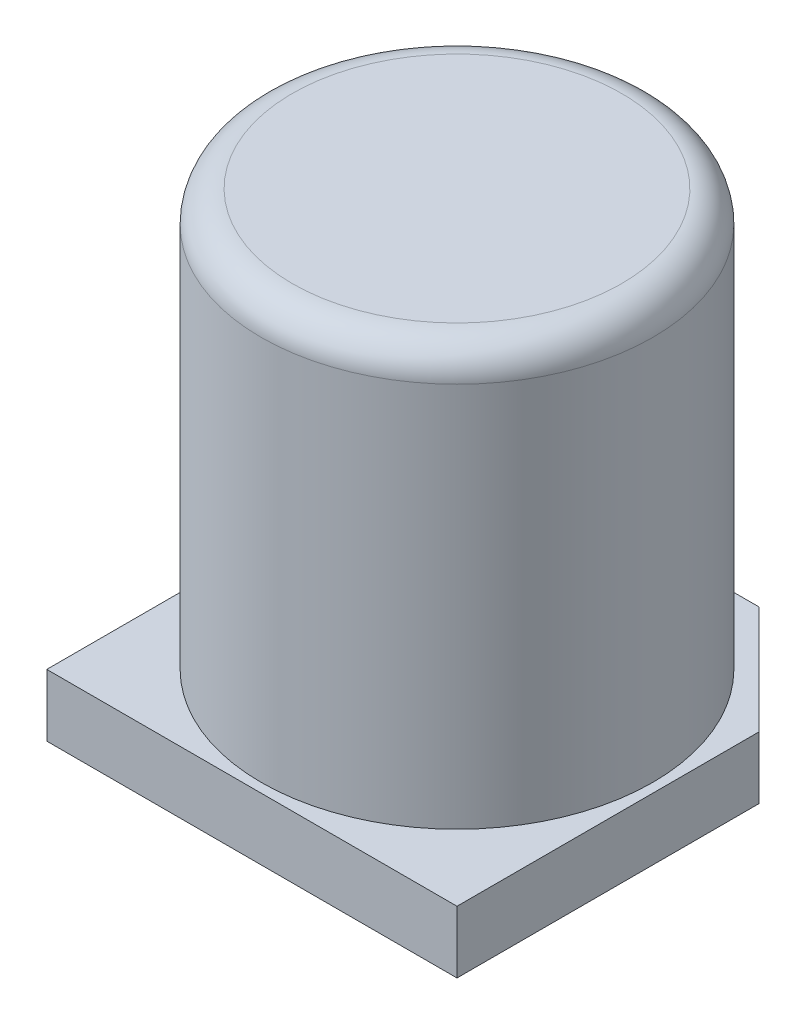
from build123d import *

# Parameters (mm, degrees)
ESBO_O1_W                = 6.6
ESBO_O1_H                = 6.6
RESSALTO_EXTRUS_O1_DEPTH = 1
ESBO_O2_W                = 3.15
ESBO_O2_H                = 6.7
CHANFRO1_SIZE            = 1.737451731
FILETE1_R                = 0.5


with BuildPart() as part:
    # Esboço1 → Ressalto-extrusão1 (new body)
    with BuildSketch(Plane.XZ):
        Rectangle(ESBO_O1_W, ESBO_O1_H)
    extrude(amount=-RESSALTO_EXTRUS_O1_DEPTH)

    # Esboço2 → Revolução1 (revolve)
    with BuildSketch(Plane.XY):
        with Locations((1.575, 4.35)):
            Rectangle(ESBO_O2_W, ESBO_O2_H)
    revolve(axis=Axis((0, 7.7, 0), (0, -1, 0)))

    # Chanfro1
    chanfro1_edges = [part.edges().sort_by_distance(p)[0] for p in [
        (3.3, 0.5, -3.3),
        (-3.3, 0.5, -3.3),
    ]]
    chamfer(chanfro1_edges, length=CHANFRO1_SIZE)

    # Filete1
    filete1_edges = [part.edges().sort_by_distance(p)[0] for p in [
        (-3.15, 7.7, 0),
    ]]
    fillet(filete1_edges, radius=FILETE1_R)


solid = part.part
